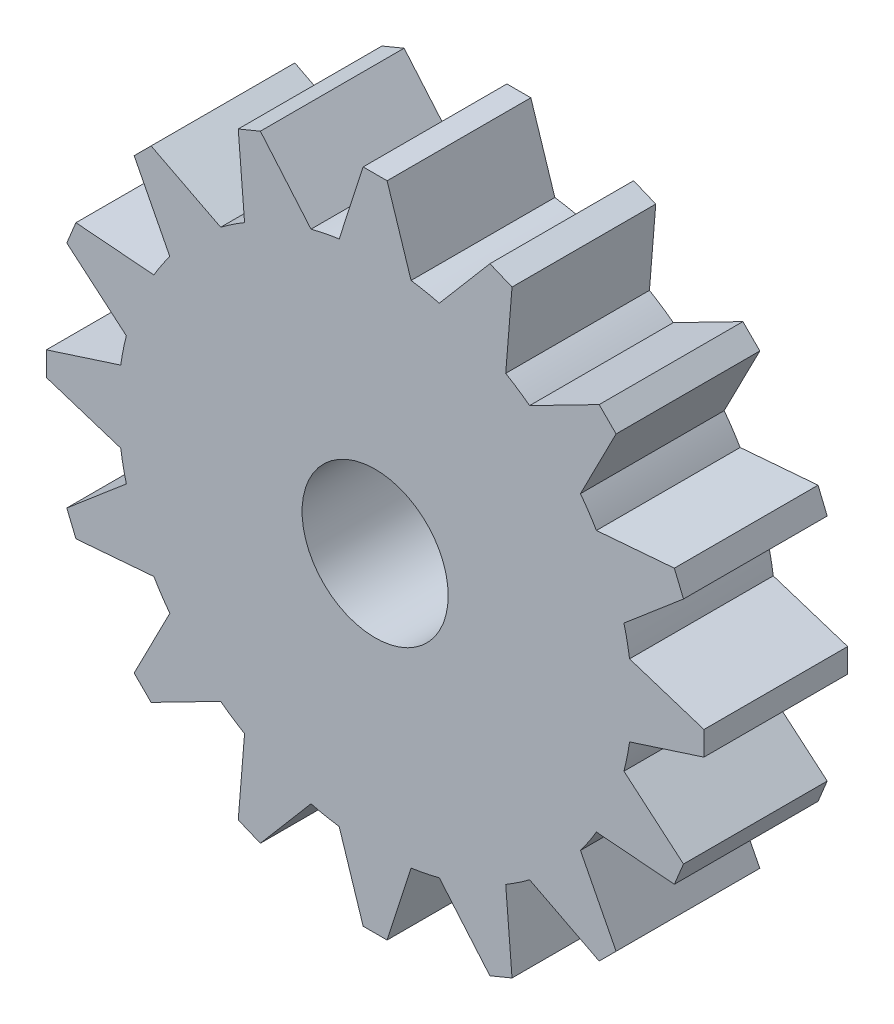
from build123d import *

# Parameters (mm, degrees)
SKETCH1_R           = 10.72611465
SKETCH1_R_2         = 3.05
BOSS_EXTRUDE1_DEPTH = 6
BOSS_EXTRUDE2_DEPTH = 6


with BuildPart() as part:
    # Sketch1 → Boss-Extrude1 (new body)
    with BuildSketch(Plane.XY):
        Circle(SKETCH1_R)
        Circle(SKETCH1_R_2, mode=Mode.SUBTRACT)
    extrude(amount=BOSS_EXTRUDE1_DEPTH)

    # Sketch3 → Boss-Extrude2 (add)
    with BuildSketch(Plane.XY.offset(6)):
        with BuildLine():
            Line((-13.72611465, 0.5), (-13.72611465, -0.5))
            Line((-13.72611465, -0.5), (-10.620597641, -1.500813525))
            ThreePointArc((-10.620597641, -1.500813525), (-10.72611465, 0), (-10.620597641, 1.500813525))
            Line((-10.620597641, 1.500813525), (-13.72611465, 0.5))
        make_face()
        with BuildLine():
            Line((-12.872618102, 4.790816901), (-10.386489254, 2.677755861))
            ThreePointArc((-10.386489254, 2.677755861), (-9.909637788, 4.10470637), (-9.237816312, 5.450897656))
            Line((-9.237816312, 5.450897656), (-12.48993467, 5.714696433))
            Line((-12.48993467, 5.714696433), (-12.872618102, 4.790816901))
        make_face()
        with BuildLine():
            ThreePointArc((-9.237816312, -5.450897656), (-9.909637788, -4.10470637), (-10.386489254, -2.677755861))
            Line((-10.386489254, -2.677755861), (-12.872618102, -4.790816901))
            Line((-12.872618102, -4.790816901), (-12.48993467, -5.714696433))
            Line((-12.48993467, -5.714696433), (-9.237816312, -5.450897656))
        make_face()
        with BuildLine():
            Line((-10.059382139, 9.352275358), (-8.571132033, 6.448661191))
            ThreePointArc((-8.571132033, 6.448661191), (-7.584508405, 7.584508405), (-6.448661191, 8.571132033))
            Line((-6.448661191, 8.571132033), (-9.352275358, 10.059382139))
            Line((-9.352275358, 10.059382139), (-10.059382139, 9.352275358))
        make_face()
        with BuildLine():
            ThreePointArc((-6.448661191, -8.571132033), (-7.584508405, -7.584508405), (-8.571132033, -6.448661191))
            Line((-8.571132033, -6.448661191), (-10.059382139, -9.352275358))
            Line((-10.059382139, -9.352275358), (-9.352275358, -10.059382139))
            Line((-9.352275358, -10.059382139), (-6.448661191, -8.571132033))
        make_face()
        with BuildLine():
            Line((-5.714696433, 12.48993467), (-5.450897656, 9.237816312))
            ThreePointArc((-5.450897656, 9.237816312), (-4.10470637, 9.909637788), (-2.677755861, 10.386489254))
            Line((-2.677755861, 10.386489254), (-4.790816901, 12.872618102))
            Line((-4.790816901, 12.872618102), (-5.714696433, 12.48993467))
        make_face()
        with BuildLine():
            ThreePointArc((-2.677755861, -10.386489254), (-4.10470637, -9.909637788), (-5.450897656, -9.237816312))
            Line((-5.450897656, -9.237816312), (-5.714696433, -12.48993467))
            Line((-5.714696433, -12.48993467), (-4.790816901, -12.872618102))
            Line((-4.790816901, -12.872618102), (-2.677755861, -10.386489254))
        make_face()
        with BuildLine():
            Line((-0.5, 13.72611465), (-1.500813525, 10.620597641))
            ThreePointArc((-1.500813525, 10.620597641), (0, 10.72611465), (1.500813525, 10.620597641))
            Line((1.500813525, 10.620597641), (0.5, 13.72611465))
            Line((0.5, 13.72611465), (-0.5, 13.72611465))
        make_face()
        with BuildLine():
            ThreePointArc((1.500813525, -10.620597641), (0, -10.72611465), (-1.500813525, -10.620597641))
            Line((-1.500813525, -10.620597641), (-0.5, -13.72611465))
            Line((-0.5, -13.72611465), (0.5, -13.72611465))
            Line((0.5, -13.72611465), (1.500813525, -10.620597641))
        make_face()
        with BuildLine():
            Line((4.790816901, 12.872618102), (2.677755861, 10.386489254))
            ThreePointArc((2.677755861, 10.386489254), (4.10470637, 9.909637788), (5.450897656, 9.237816312))
            Line((5.450897656, 9.237816312), (5.714696433, 12.48993467))
            Line((5.714696433, 12.48993467), (4.790816901, 12.872618102))
        make_face()
        with BuildLine():
            ThreePointArc((5.450897656, -9.237816312), (4.10470637, -9.909637788), (2.677755861, -10.386489254))
            Line((2.677755861, -10.386489254), (4.790816901, -12.872618102))
            Line((4.790816901, -12.872618102), (5.714696433, -12.48993467))
            Line((5.714696433, -12.48993467), (5.450897656, -9.237816312))
        make_face()
        with BuildLine():
            Line((9.352275358, 10.059382139), (6.448661191, 8.571132033))
            ThreePointArc((6.448661191, 8.571132033), (7.584508405, 7.584508405), (8.571132033, 6.448661191))
            Line((8.571132033, 6.448661191), (10.059382139, 9.352275358))
            Line((10.059382139, 9.352275358), (9.352275358, 10.059382139))
        make_face()
        with BuildLine():
            ThreePointArc((8.571132033, -6.448661191), (7.584508405, -7.584508405), (6.448661191, -8.571132033))
            Line((6.448661191, -8.571132033), (9.352275358, -10.059382139))
            Line((9.352275358, -10.059382139), (10.059382139, -9.352275358))
            Line((10.059382139, -9.352275358), (8.571132033, -6.448661191))
        make_face()
        with BuildLine():
            Line((12.48993467, 5.714696433), (9.237816312, 5.450897656))
            ThreePointArc((9.237816312, 5.450897656), (9.909637788, 4.10470637), (10.386489254, 2.677755861))
            Line((10.386489254, 2.677755861), (12.872618102, 4.790816901))
            Line((12.872618102, 4.790816901), (12.48993467, 5.714696433))
        make_face()
        with BuildLine():
            ThreePointArc((10.386489254, -2.677755861), (9.909637788, -4.10470637), (9.237816312, -5.450897656))
            Line((9.237816312, -5.450897656), (12.48993467, -5.714696433))
            Line((12.48993467, -5.714696433), (12.872618102, -4.790816901))
            Line((12.872618102, -4.790816901), (10.386489254, -2.677755861))
        make_face()
        with BuildLine():
            Line((13.72611465, 0.5), (10.620597641, 1.500813525))
            ThreePointArc((10.620597641, 1.500813525), (10.72611465, 0), (10.620597641, -1.500813525))
            Line((10.620597641, -1.500813525), (13.72611465, -0.5))
            Line((13.72611465, -0.5), (13.72611465, 0.5))
        make_face()
    extrude(amount=-BOSS_EXTRUDE2_DEPTH)


solid = part.part
